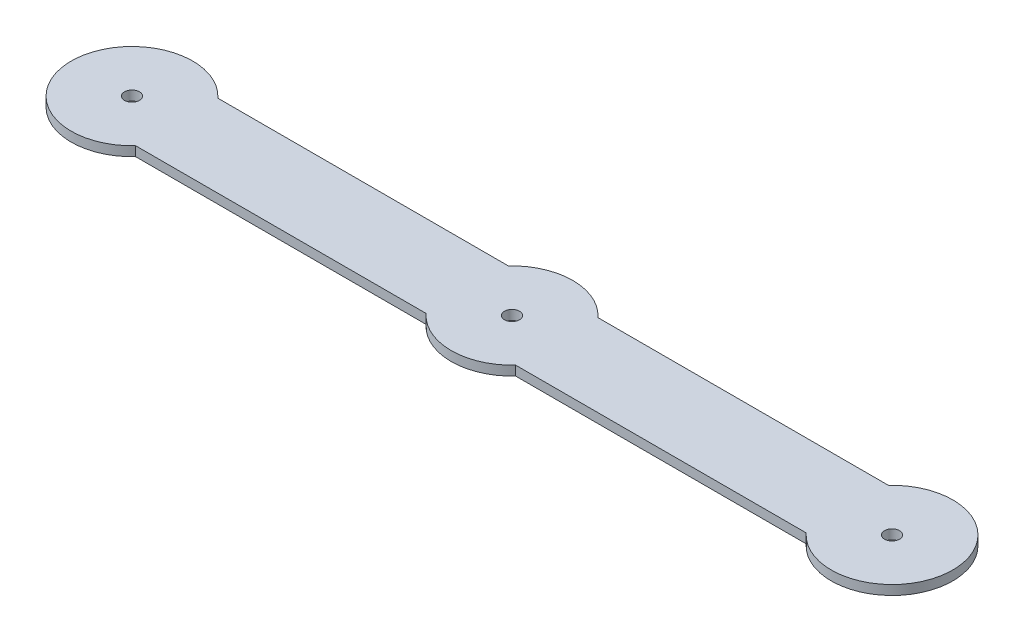
from build123d import *

# Parameters (mm, degrees)
BOSS_EXTRUDE1_DEPTH     = 2.54
SKETCH2_R               = 2
CUT_EXTRUDE1_DEPTH      = 1
CUT_EXTRUDE1_DEPTH_BACK = 3.54


with BuildPart() as part:
    # Sketch1 → Boss-Extrude1 (new body)
    with BuildSketch(Plane(origin=(0, 0, 0), x_dir=(1, 0, 0), z_dir=(0, 1, 0))):
        with BuildLine():
            Line((-89.636017598, 11), (-11.963982402, 11))
            ThreePointArc((-11.963982402, 11), (0, 16.252288298), (11.963982402, 11))
            Line((11.963982402, 11), (89.636017598, 11))
            ThreePointArc((89.636017598, 11), (117.852288298, 0), (89.636017598, -11))
            Line((89.636017598, -11), (11.963982402, -11))
            ThreePointArc((11.963982402, -11), (0, -16.252288298), (-11.963982402, -11))
            Line((-11.963982402, -11), (-89.636017598, -11))
            ThreePointArc((-89.636017598, -11), (-117.852288298, 0), (-89.636017598, 11))
        make_face()
    extrude(amount=BOSS_EXTRUDE1_DEPTH)

    # Sketch2 → Cut-Extrude1 (cut, two sides)
    with BuildSketch(Plane(origin=(0, 2.54, 0), x_dir=(1, 0, 0), z_dir=(0, 1, 0))) as cut_extrude1_sk:
        with Locations((-101.6, 0)):
            Circle(SKETCH2_R)
        with Locations((101.6, 0)):
            Circle(SKETCH2_R)
        Circle(SKETCH2_R)
    extrude(amount=CUT_EXTRUDE1_DEPTH, mode=Mode.SUBTRACT)
    extrude(cut_extrude1_sk.sketch, amount=-CUT_EXTRUDE1_DEPTH_BACK, mode=Mode.SUBTRACT)


solid = part.part
